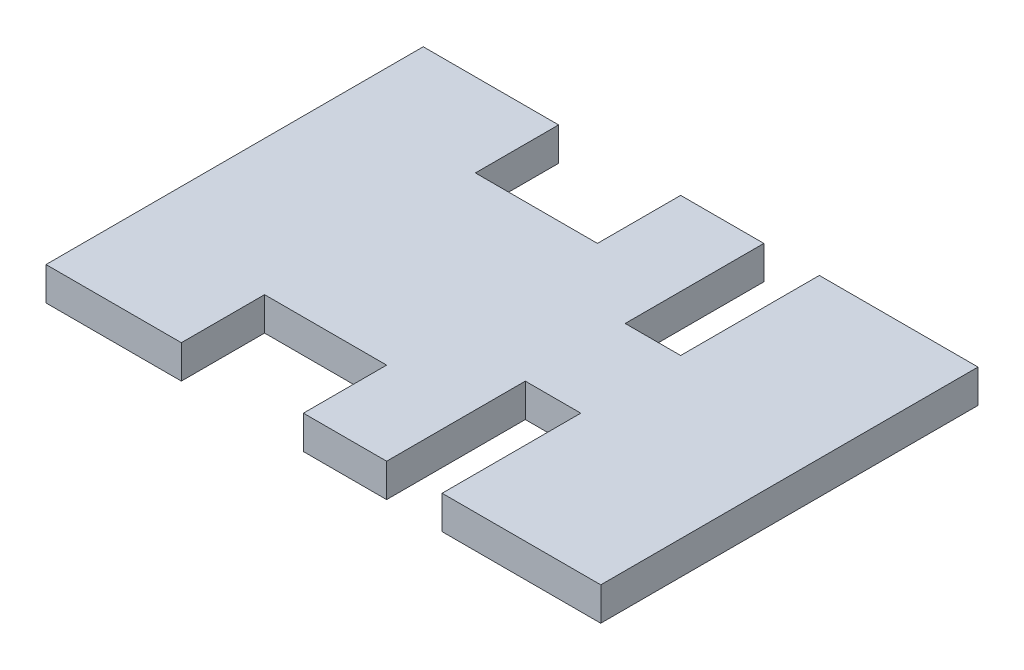
from build123d import *

# Parameters (mm, degrees)
SKETCH1_W           = 100
SKETCH1_H           = 68
BOSS_EXTRUDE1_DEPTH = 6
SKETCH2_W           = 10
SKETCH2_H           = 25
SKETCH2_W_2         = 22
SKETCH2_H_2         = 15
CUT_EXTRUDE1_DEPTH  = 7


with BuildPart() as part:
    # Sketch1 → Boss-Extrude1 (new body)
    with BuildSketch(Plane(origin=(0, 0, 0), x_dir=(1, 0, 0), z_dir=(0, 1, 0))):
        Rectangle(SKETCH1_W, SKETCH1_H)
    extrude(amount=BOSS_EXTRUDE1_DEPTH)

    # Sketch2 → Cut-Extrude1 (cut, through all)
    with BuildSketch(Plane(origin=(0, 6, 0), x_dir=(1, 0, 0), z_dir=(0, 1, 0))):
        with Locations((16.4, -21.5)):
            Rectangle(SKETCH2_W, SKETCH2_H)
        with Locations((-14.6, -26.5)):
            Rectangle(SKETCH2_W_2, SKETCH2_H_2)
    cut_extrude1 = extrude(amount=-CUT_EXTRUDE1_DEPTH, mode=Mode.SUBTRACT)

    # Mirror1: Cut-Extrude1 across plane
    add(cut_extrude1.mirror(Plane.XY), mode=Mode.SUBTRACT)


solid = part.part
